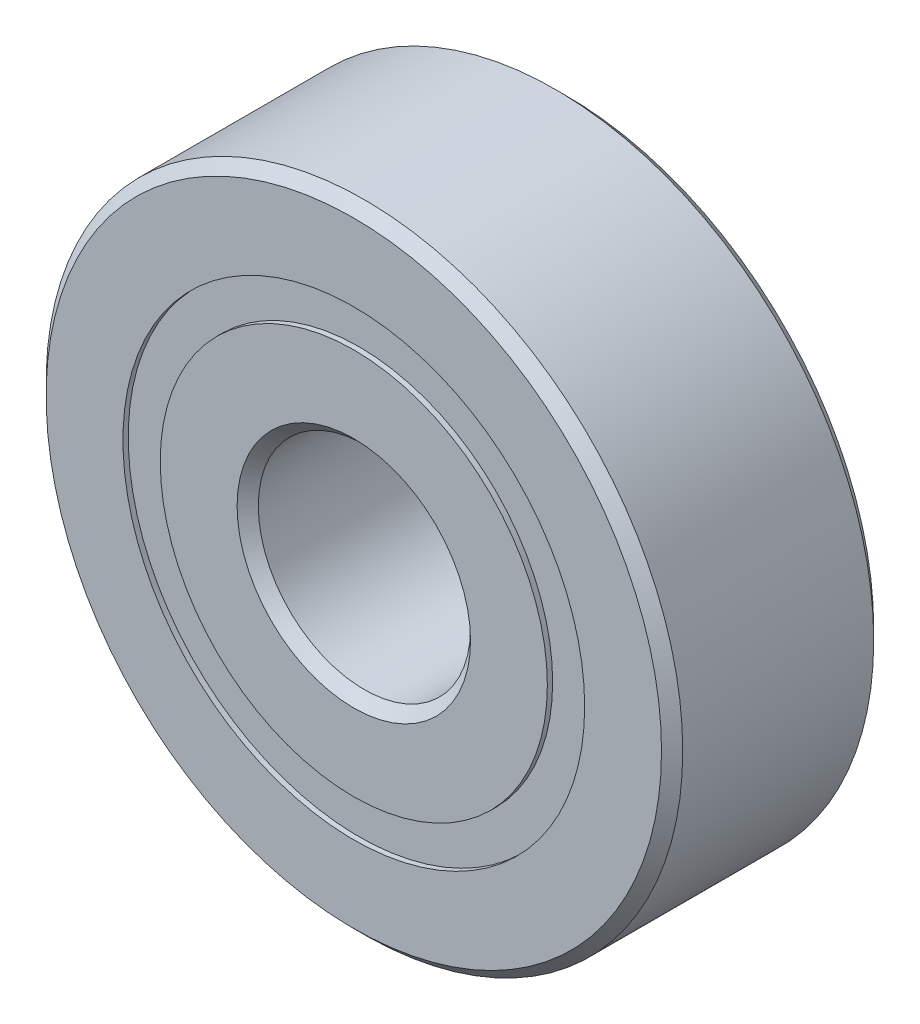
from build123d import *

# Parameters (mm, degrees)
CIRPATTERN1_COUNT = 12
SKETCH5_W         = 0.944081583
SKETCH5_H         = 0.703296704


with BuildPart() as part:
    # Sketch1 → Revolve1 (revolve)
    with BuildSketch(Plane(origin=(0, 0, 0), x_dir=(0, 0, -1), z_dir=(1, 0, 0))):
        with BuildLine():
            Line((1.8, 6), (-1.8, 6))
            Line((-1.8, 6), (-2, 5.8))
            Line((-2, 5.8), (-2, 4.351648352))
            Line((-2, 4.351648352), (-0.888888889, 4.351648352))
            ThreePointArc((-0.888888889, 4.351648352), (0, 4.955918417), (0.888888889, 4.351648352))
            Line((0.888888889, 4.351648352), (2, 4.351648352))
            Line((2, 4.351648352), (2, 5.8))
            Line((2, 5.8), (1.8, 6))
        make_face()
    revolve(axis=Axis((0, 0, 2), (0, 0, -1)))


with BuildPart() as body_2:
    # Sketch3 → Revolve3 (revolve)
    with BuildSketch(Plane(origin=(0, 0, 0), x_dir=(0, 0, -1), z_dir=(1, 0, 0))):
        with BuildLine():
            Line((-2, 3.648351648), (-0.888888889, 3.648351648))
            ThreePointArc((-0.888888889, 3.648351648), (0, 3.044081583), (0.888888889, 3.648351648))
            Line((0.888888889, 3.648351648), (2, 3.648351648))
            Line((2, 3.648351648), (2, 2.2))
            Line((2, 2.2), (1.8, 2))
            Line((1.8, 2), (-1.8, 2))
            Line((-1.8, 2), (-2, 2.2))
            Line((-2, 2.2), (-2, 3.648351648))
        make_face()
    revolve(axis=Axis((0, 0, 2), (0, 0, -1)))


with BuildPart() as body_3:
    # Sketch4 → Revolve4 (revolve)
    with BuildSketch(Plane(origin=(0, 0, 0), x_dir=(0, 0, -1), z_dir=(1, 0, 0))):
        with BuildLine():
            Line((-0.955918417, 4), (0.955918417, 4))
            ThreePointArc((0.955918417, 4), (0, 4.955918417), (-0.955918417, 4))
        make_face()
    revolve(axis=Axis((0, 4, 0.955918417), (0, 0, -1)))


with BuildPart() as cirpattern1_1:
    # CirPattern1: pattern copy
    add(body_3.part.rotate(Axis((0, 0, 0), (0, 0, 1)), 1 * 360 / CIRPATTERN1_COUNT))


with BuildPart() as cirpattern1_2:
    # CirPattern1: pattern copy
    add(body_3.part.rotate(Axis((0, 0, 0), (0, 0, 1)), 2 * 360 / CIRPATTERN1_COUNT))


with BuildPart() as cirpattern1_3:
    # CirPattern1: pattern copy
    add(body_3.part.rotate(Axis((0, 0, 0), (0, 0, 1)), 3 * 360 / CIRPATTERN1_COUNT))


with BuildPart() as cirpattern1_4:
    # CirPattern1: pattern copy
    add(body_3.part.rotate(Axis((0, 0, 0), (0, 0, 1)), 4 * 360 / CIRPATTERN1_COUNT))


with BuildPart() as cirpattern1_5:
    # CirPattern1: pattern copy
    add(body_3.part.rotate(Axis((0, 0, 0), (0, 0, 1)), 5 * 360 / CIRPATTERN1_COUNT))


with BuildPart() as cirpattern1_6:
    # CirPattern1: pattern copy
    add(body_3.part.rotate(Axis((0, 0, 0), (0, 0, 1)), 6 * 360 / CIRPATTERN1_COUNT))


with BuildPart() as cirpattern1_7:
    # CirPattern1: pattern copy
    add(body_3.part.rotate(Axis((0, 0, 0), (0, 0, 1)), 7 * 360 / CIRPATTERN1_COUNT))


with BuildPart() as cirpattern1_8:
    # CirPattern1: pattern copy
    add(body_3.part.rotate(Axis((0, 0, 0), (0, 0, 1)), 8 * 360 / CIRPATTERN1_COUNT))


with BuildPart() as cirpattern1_9:
    # CirPattern1: pattern copy
    add(body_3.part.rotate(Axis((0, 0, 0), (0, 0, 1)), 9 * 360 / CIRPATTERN1_COUNT))


with BuildPart() as cirpattern1_10:
    # CirPattern1: pattern copy
    add(body_3.part.rotate(Axis((0, 0, 0), (0, 0, 1)), 10 * 360 / CIRPATTERN1_COUNT))


with BuildPart() as cirpattern1_11:
    # CirPattern1: pattern copy
    add(body_3.part.rotate(Axis((0, 0, 0), (0, 0, 1)), 11 * 360 / CIRPATTERN1_COUNT))


with BuildPart() as body_15:
    # Sketch5 → Revolve5 (revolve)
    with BuildSketch(Plane(origin=(0, 0, 0), x_dir=(0, 0, -1), z_dir=(1, 0, 0))):
        with Locations((-1.427959209, 4)):
            Rectangle(SKETCH5_W, SKETCH5_H)
        with Locations((1.427959209, 4)):
            Rectangle(SKETCH5_W, SKETCH5_H)
    revolve(axis=Axis((0, 0, 2), (0, 0, -1)))


solid = Compound([part.part, body_2.part, body_3.part, cirpattern1_1.part, cirpattern1_2.part, cirpattern1_3.part, cirpattern1_4.part, cirpattern1_5.part, cirpattern1_6.part, cirpattern1_7.part, cirpattern1_8.part, cirpattern1_9.part, cirpattern1_10.part, cirpattern1_11.part, body_15.part])
